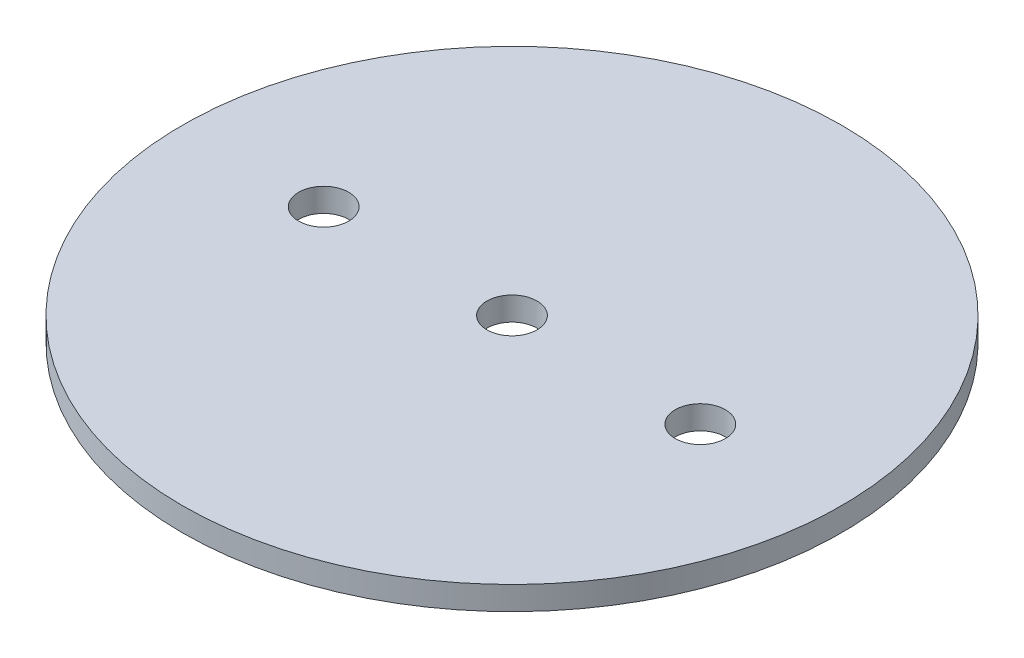
from build123d import *

# Parameters (mm, degrees)
SKETCH1_R                   = 44.45
BOSS_EXTRUDE1_DEPTH         = 1.5875
F_1_4_CLEARANCE_HOLE1_D     = 6.7564
F_1_4_CLEARANCE_HOLE1_DEPTH = 48.770172657
F_1_4_CLEARANCE_HOLE1_TIP   = 2.029827343


with BuildPart() as part:
    # Sketch1 → Boss-Extrude1 (new body, symmetric)
    with BuildSketch(Plane(origin=(0, 0, 0), x_dir=(1, 0, 0), z_dir=(0, 1, 0))):
        Circle(SKETCH1_R)
    extrude(amount=BOSS_EXTRUDE1_DEPTH, both=True)

    # 1/4 Clearance Hole1
    with Locations(Plane(origin=(0, 1.5875, 0), x_dir=(1, 0, 0), z_dir=(0, 1, 0))):
        with Locations((25.4, 0), (-25.4, 0), (0, 0)):
            Hole(F_1_4_CLEARANCE_HOLE1_D / 2, depth=F_1_4_CLEARANCE_HOLE1_DEPTH)
            with Locations((0, 0, -(F_1_4_CLEARANCE_HOLE1_DEPTH + F_1_4_CLEARANCE_HOLE1_TIP / 2))):  # 118° drill point
                Cone(0, F_1_4_CLEARANCE_HOLE1_D / 2, F_1_4_CLEARANCE_HOLE1_TIP, mode=Mode.SUBTRACT)


solid = part.part
